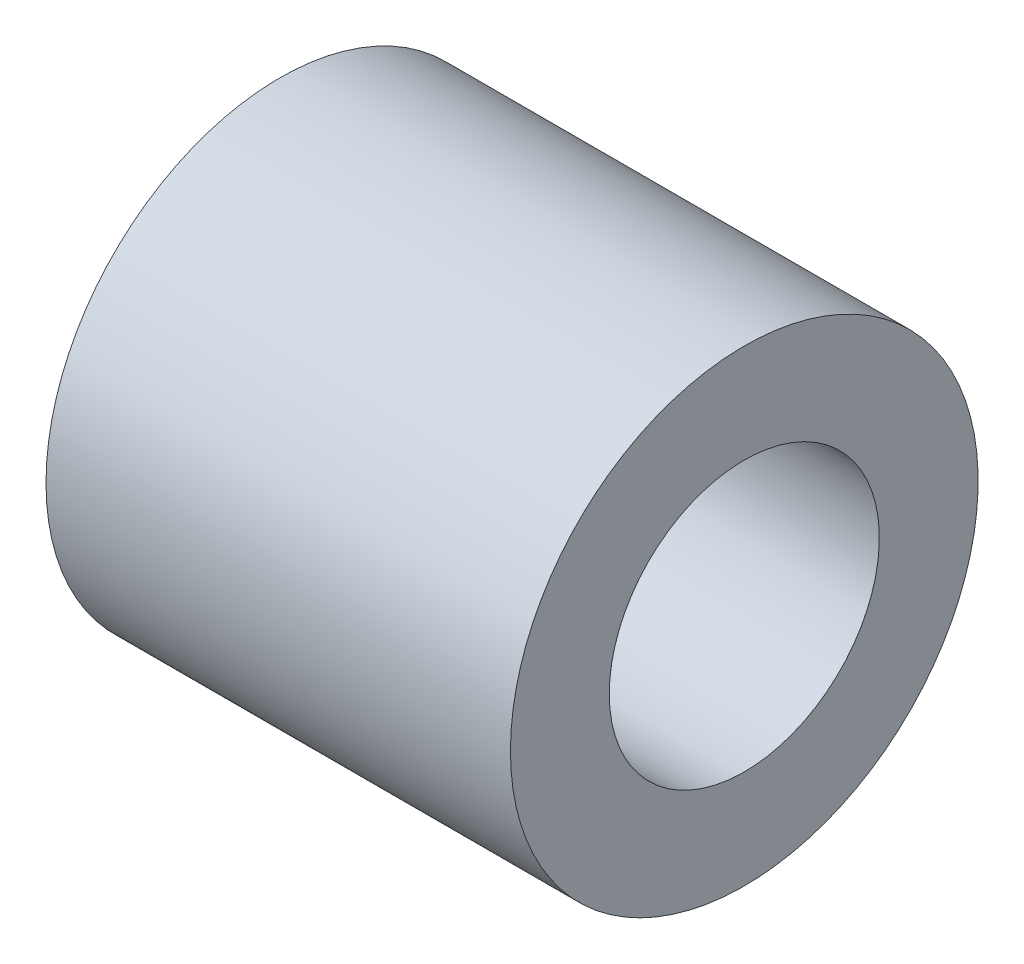
from build123d import *

# Parameters (mm, degrees)
SKETCH1_W = 14.1
SKETCH1_H = 3


with BuildPart() as part:
    # Sketch1 → Revolve1 (revolve)
    with BuildSketch(Plane(origin=(0, 0, 0), x_dir=(1, 0, 0), z_dir=(0, 1, 0))):
        with Locations((7.05, -5.6)):
            Rectangle(SKETCH1_W, SKETCH1_H)
    revolve(axis=Axis((0, 0, 0), (1, 0, 0)))


solid = part.part
